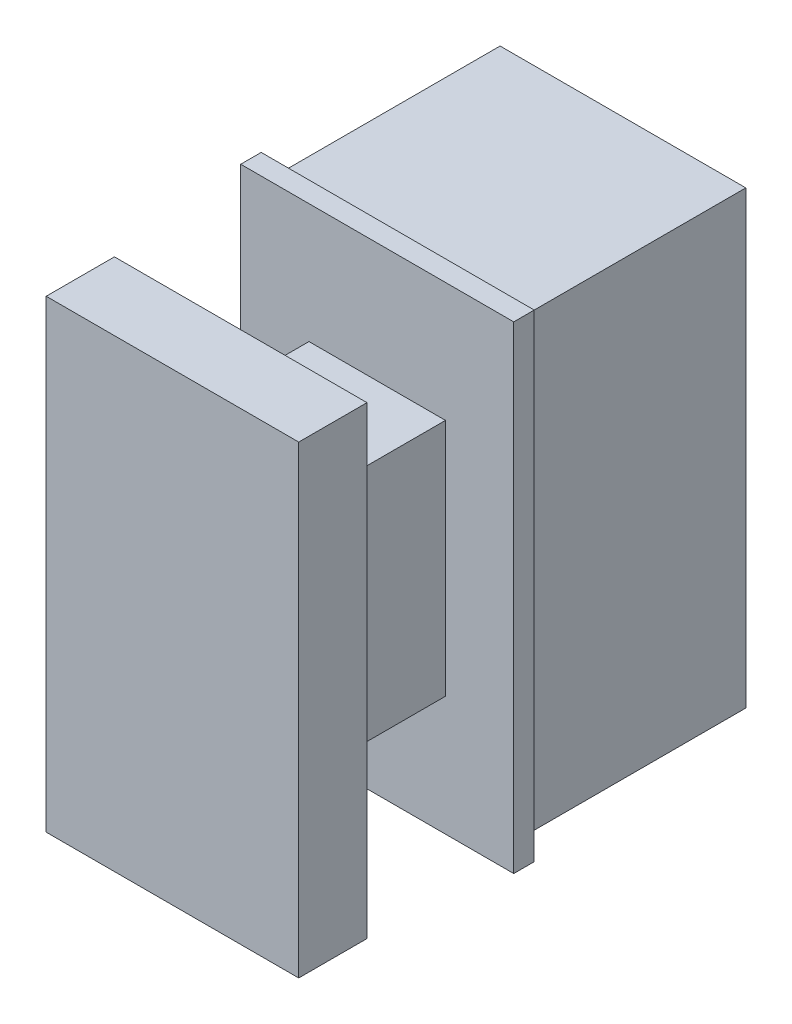
from build123d import *

# Parameters (mm, degrees)
SCHIZZO1_W                   = 4
SCHIZZO1_H                   = 7
ESTRUSIONE_ESTRUSIONE1_DEPTH = 0.3
SCHIZZO2_W                   = 3.6
SCHIZZO2_H                   = 6.6
ESTRUSIONE_ESTRUSIONE2_DEPTH = 3.3
SCHIZZO3_W                   = 3.2
SCHIZZO3_H                   = 6.2
TAGLIO_ESTRUSIONE1_DEPTH     = 4.3
SCHIZZO6_W                   = 2
SCHIZZO6_H                   = 3.5
ESTRUSIONE_ESTRUSIONE3_DEPTH = 2.3
SCHIZZO7_W                   = 3.7
SCHIZZO7_H                   = 6.8
ESTRUSIONE_ESTRUSIONE4_DEPTH = 1


with BuildPart() as part:
    # Schizzo1 → Estrusione-Estrusione1 (new body)
    with BuildSketch(Plane.XY):
        with Locations((2, 3.5)):
            Rectangle(SCHIZZO1_W, SCHIZZO1_H)
    extrude(amount=ESTRUSIONE_ESTRUSIONE1_DEPTH)

    # Schizzo2 → Estrusione-Estrusione2 (add)
    with BuildSketch(Plane.XY):
        with Locations((2, 3.5)):
            Rectangle(SCHIZZO2_W, SCHIZZO2_H)
    extrude(amount=-ESTRUSIONE_ESTRUSIONE2_DEPTH)

    # Schizzo3 → Taglio-Estrusione1 (cut, through all)
    with BuildSketch(Plane.XY):
        with Locations((2, 3.5)):
            Rectangle(SCHIZZO3_W, SCHIZZO3_H)
    extrude(amount=-TAGLIO_ESTRUSIONE1_DEPTH, mode=Mode.SUBTRACT)

    # Schizzo6 → Estrusione-Estrusione3 (add)
    with BuildSketch(Plane.XY):
        with Locations((2, 3.5)):
            Rectangle(SCHIZZO6_W, SCHIZZO6_H)
    extrude(amount=ESTRUSIONE_ESTRUSIONE3_DEPTH)

    # Schizzo7 → Estrusione-Estrusione4 (add)
    with BuildSketch(Plane.XY.offset(2.3)):
        with Locations((2, 3.5)):
            Rectangle(SCHIZZO7_W, SCHIZZO7_H)
    extrude(amount=ESTRUSIONE_ESTRUSIONE4_DEPTH)


solid = part.part
